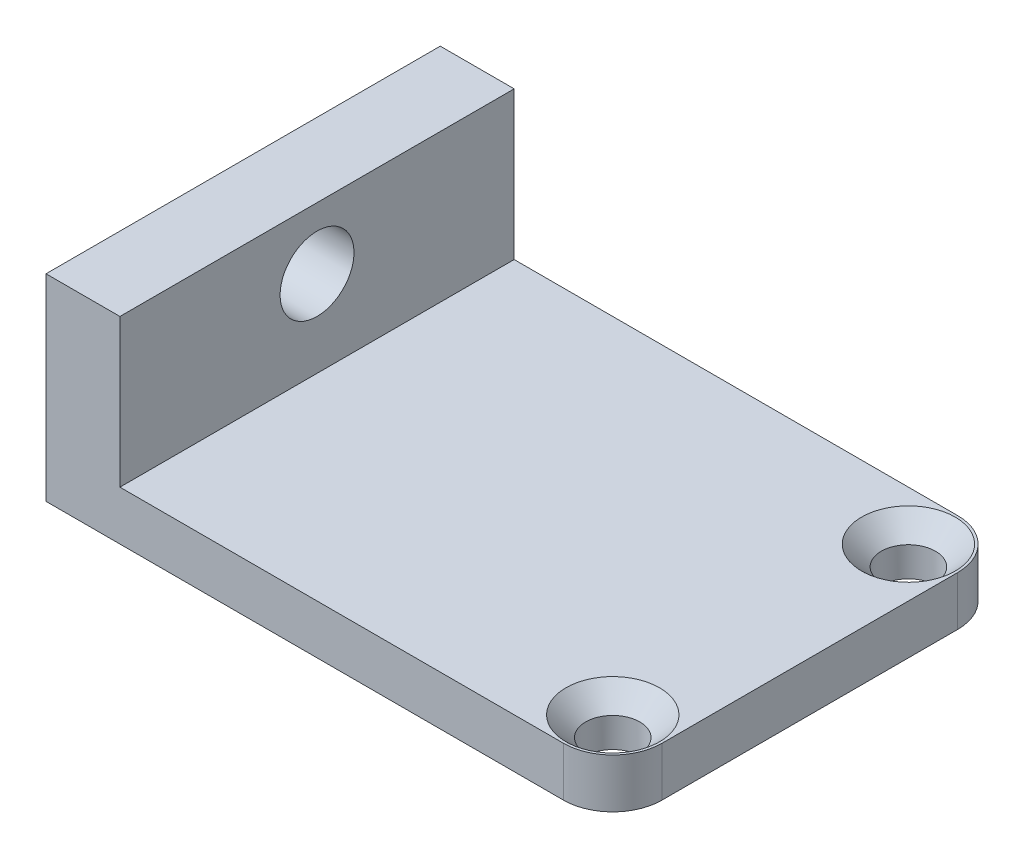
from build123d import *

# Parameters (mm, degrees)
BOSS_EXTRUDE1_DEPTH = 16
SKETCH2_R           = 1.1
CUT_EXTRUDE1_DEPTH  = 2
SKETCH3_R           = 1.5
CUT_EXTRUDE2_DEPTH  = 24
CHAMFER1_SIZE       = 0.8
FILLET1_R           = 2


with BuildPart() as part:
    # Sketch1 → Boss-Extrude1 (new body)
    with BuildSketch(Plane.XY):
        Polygon((0, 0), (0, 8), (3, 8), (3, 2), (23, 2), (23, 0), align=None)
    extrude(amount=BOSS_EXTRUDE1_DEPTH)

    # Sketch2 → Cut-Extrude1 (cut)
    with BuildSketch(Plane(origin=(0, 2, 0), x_dir=(1, 0, 0), z_dir=(0, 1, 0))):
        with Locations((21, -2)):
            Circle(SKETCH2_R)
        with Locations((21, -14)):
            Circle(SKETCH2_R)
    extrude(amount=-CUT_EXTRUDE1_DEPTH, mode=Mode.SUBTRACT)

    # Sketch3 → Cut-Extrude2 (cut, through all)
    with BuildSketch(Plane.ZY):
        with Locations((8, 5.5)):
            Circle(SKETCH3_R)
    extrude(amount=-CUT_EXTRUDE2_DEPTH, mode=Mode.SUBTRACT)

    # Chamfer1
    chamfer1_edges = [part.edges().sort_by_distance(p)[0] for p in [
        (19.9, 2, 2),
        (19.9, 2, 14),
    ]]
    chamfer(chamfer1_edges, length=CHAMFER1_SIZE)

    # Fillet1
    fillet1_edges = [part.edges().sort_by_distance(p)[0] for p in [
        (23, 1, 16),
        (23, 1, 0),
    ]]
    fillet(fillet1_edges, radius=FILLET1_R)


solid = part.part
